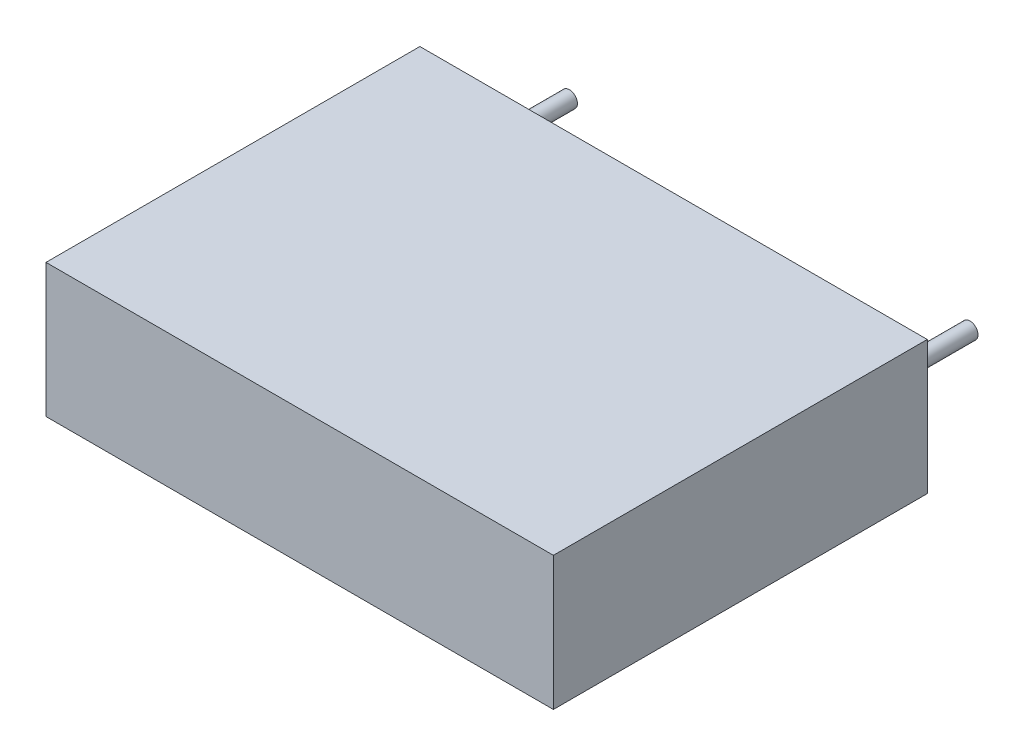
from build123d import *

# Parameters (mm, degrees)
ESQUISSE1_W        = 19
ESQUISSE1_H        = 5
BOSS_EXTRU_1_DEPTH = 14
ESQUISSE2_R        = 0.3
BOSS_EXTRU_2_DEPTH = 3.6


with BuildPart() as part:
    # Esquisse1 → Boss.-Extru.1 (new body)
    with BuildSketch(Plane.XY):
        Rectangle(ESQUISSE1_W, ESQUISSE1_H)
    extrude(amount=BOSS_EXTRU_1_DEPTH)

    # Esquisse2 → Boss.-Extru.2 (add)
    with BuildSketch(Plane(origin=(0, 0, 0), x_dir=(-1, 0, 0), z_dir=(0, 0, -1))):
        with Locations((-7.5, 0)):
            Circle(ESQUISSE2_R)
        with Locations((7.5, 0)):
            Circle(ESQUISSE2_R)
    extrude(amount=BOSS_EXTRU_2_DEPTH)


solid = part.part
